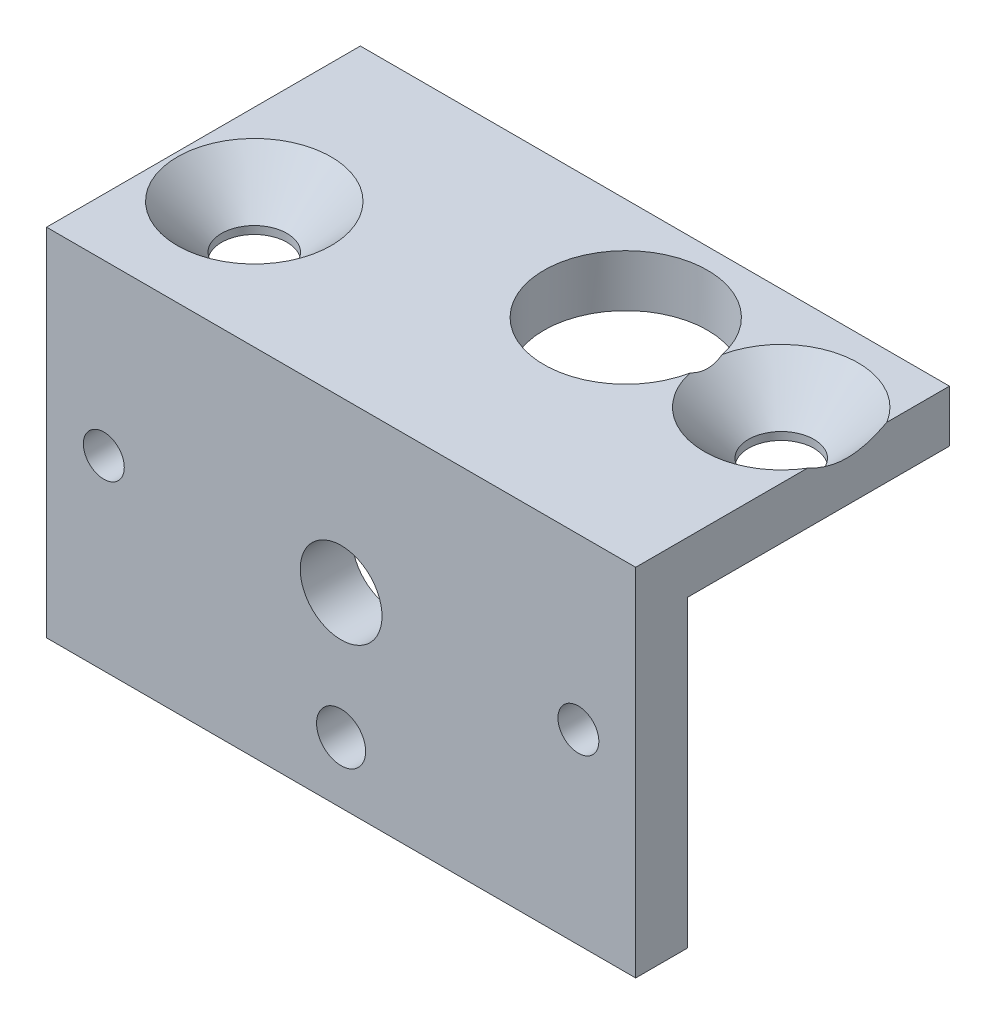
from build123d import *

# Parameters (mm, degrees)
SKETCH1_W                                            = 36
SKETCH1_H                                            = 21.735371596
SKETCH1_R                                            = 1.25
SKETCH1_R_2                                          = 2.5
SKETCH1_R_3                                          = 1.5
BOSS_EXTRUDE1_DEPTH                                  = 3.175
SKETCH2_W                                            = 36
SKETCH2_H                                            = 3.175
BOSS_EXTRUDE2_DEPTH                                  = 16
SKETCH3_R                                            = 5
SKETCH3_R_2                                          = 2
CUT_EXTRUDE1_DEPTH                                   = 10
ESCAREADO_PARA_PARAFUSO_DE_M_QUINA_COM_C_D           = 4
ESCAREADO_PARA_PARAFUSO_DE_M_QUINA_COM_C_CSINK_D     = 9.4
ESCAREADO_PARA_PARAFUSO_DE_M_QUINA_COM_C_CSINK_ANGLE = 90


with BuildPart() as part:
    # Sketch1 → Boss-Extrude1 (new body)
    with BuildSketch(Plane.XY):
        with Locations((0, 2)):
            Rectangle(SKETCH1_W, SKETCH1_H)
        with Locations((-14.5, 2.527685798)):
            Circle(SKETCH1_R, mode=Mode.SUBTRACT)
        with Locations((14.5, 2.527685798)):
            Circle(SKETCH1_R, mode=Mode.SUBTRACT)
        with Locations((0, 2.527685798)):
            Circle(SKETCH1_R_2, mode=Mode.SUBTRACT)
        with Locations((0, -5.132314202)):
            Circle(SKETCH1_R_3, mode=Mode.SUBTRACT)
    extrude(amount=BOSS_EXTRUDE1_DEPTH)

    # Sketch2 → Boss-Extrude2 (add)
    with BuildSketch(Plane(origin=(0, 0, 0), x_dir=(-1, 0, 0), z_dir=(0, 0, -1))):
        with Locations((0, 11.280185798)):
            Rectangle(SKETCH2_W, SKETCH2_H)
    extrude(amount=BOSS_EXTRUDE2_DEPTH)

    # Sketch3 → Cut-Extrude1 (cut)
    with BuildSketch(Plane.XZ.offset(-9.692685798)):
        with Locations((4.475, -9.744145571)):
            Circle(SKETCH3_R)
        with Locations((-13.025, -4.544145571)):
            Circle(SKETCH3_R_2)
        with Locations((13.975, -9.744145571)):
            Circle(SKETCH3_R_2)
    extrude(amount=-CUT_EXTRUDE1_DEPTH, mode=Mode.SUBTRACT)

    # Escareado para parafuso de máquina com cabeça chata de M42 (through all)
    with Locations(Plane(origin=(0, 12.867685798, 0), x_dir=(-1, 0, 0), z_dir=(0, 1, 0))):
        with Locations((13.025, -4.544145571), (-13.975, -9.744145571)):
            CounterSinkHole(ESCAREADO_PARA_PARAFUSO_DE_M_QUINA_COM_C_D / 2, ESCAREADO_PARA_PARAFUSO_DE_M_QUINA_COM_C_CSINK_D / 2, counter_sink_angle=ESCAREADO_PARA_PARAFUSO_DE_M_QUINA_COM_C_CSINK_ANGLE)


solid = part.part
